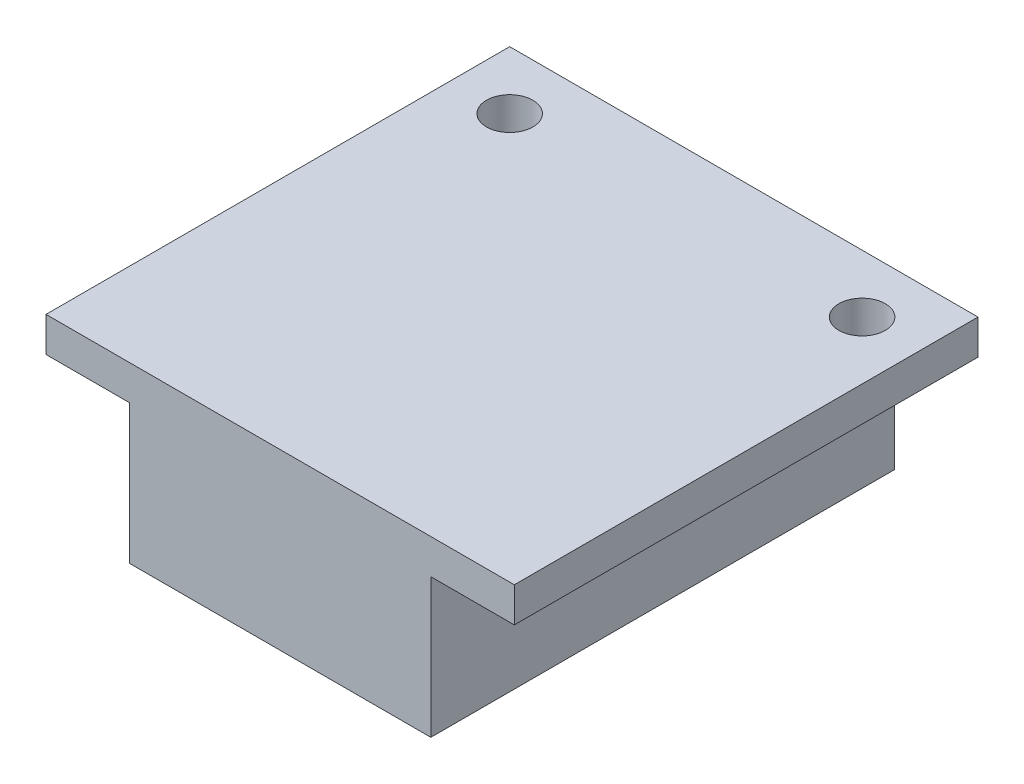
from build123d import *

# Parameters (mm, degrees)
SKETCH_1_W          = 20.2
SKETCH_1_H          = 1.5
EXTRUDE_1_DEPTH     = 20
SKETCH_2_W          = 13
SKETCH_2_H          = 6
EXTRUDE_2_DEPTH     = 20
SKETCH_3_R          = 1
CUT_EXTRUDE_1_DEPTH = 2.5


with BuildPart() as part:
    # 草图1 → 凸台-拉伸1 (new body)
    with BuildSketch(Plane.XY):
        with Locations((-6.159701493, 0.302238806)):
            Rectangle(SKETCH_1_W, SKETCH_1_H)
    extrude(amount=-EXTRUDE_1_DEPTH)

    # 草图2 → 凸台-拉伸2 (add)
    with BuildSketch(Plane.XY):
        with Locations((-6.159701493, -3.447761194)):
            Rectangle(SKETCH_2_W, SKETCH_2_H)
    extrude(amount=-EXTRUDE_2_DEPTH)

    # 草图3 → 切除-拉伸1 (cut, through all)
    with BuildSketch(Plane(origin=(0, -0.447761194, 0), x_dir=(-1, 0, 0), z_dir=(0, -1, 0))):
        with Locations((-1.440298507, 17.5)):
            Circle(SKETCH_3_R)
        with Locations((13.759701493, 17.5)):
            Circle(SKETCH_3_R)
    extrude(amount=-CUT_EXTRUDE_1_DEPTH, mode=Mode.SUBTRACT)


solid = part.part
